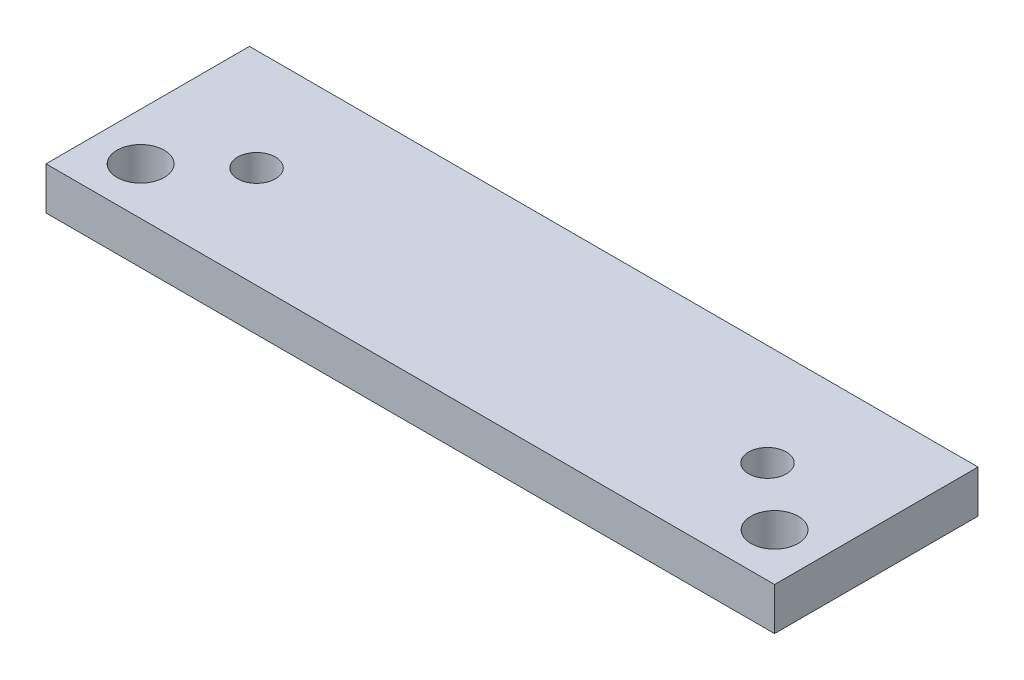
from build123d import *

# Parameters (mm, degrees)
SKETCH_1_W      = 77
SKETCH_1_H      = 21.5
SKETCH_1_R      = 2
SKETCH_1_R_2    = 2.5
EXTRUDE_1_DEPTH = 4.5


with BuildPart() as part:
    # 草图1 → 凸台-拉伸1 (new body)
    with BuildSketch(Plane(origin=(0, 0, 0), x_dir=(1, 0, 0), z_dir=(0, 1, 0))):
        with Locations((38.5, 10.75)):
            Rectangle(SKETCH_1_W, SKETCH_1_H)
        with Locations((11.5, 10.75)):
            Circle(SKETCH_1_R, mode=Mode.SUBTRACT)
        with Locations((65.5, 10.75)):
            Circle(SKETCH_1_R, mode=Mode.SUBTRACT)
        with Locations((5, 5)):
            Circle(SKETCH_1_R_2, mode=Mode.SUBTRACT)
        with Locations((72, 5)):
            Circle(SKETCH_1_R_2, mode=Mode.SUBTRACT)
    extrude(amount=EXTRUDE_1_DEPTH)


solid = part.part
